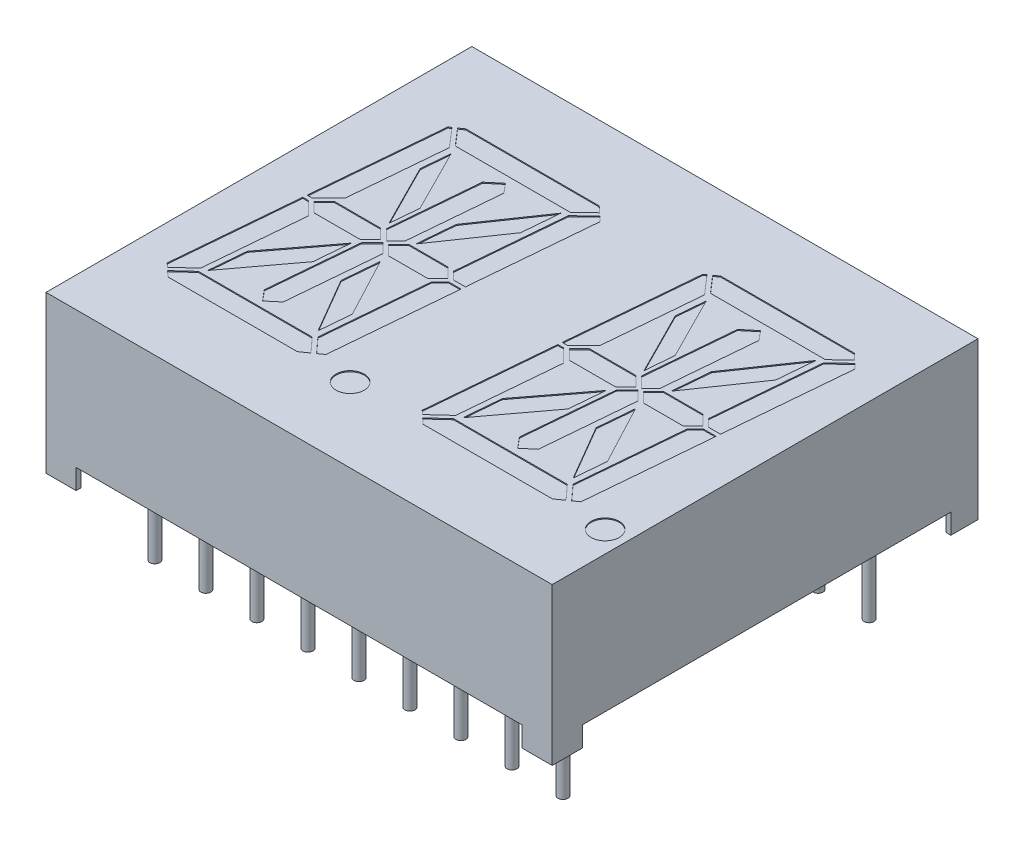
from build123d import *
from build123d.topology import SkipClean

# Parameters (mm, degrees)
SKETCH1_W           = 25.2
SKETCH1_H           = 21.2
EXTRUDE2_DEPTH      = 7.8
SKETCH6_R           = 0.7
CUT_EXTRUDE4_DEPTH  = 0.05
SKETCH7_R           = 0.25
EXTRUDE4_DEPTH      = 4
SKETCH9_W           = 18.348433105
SKETCH9_H           = 1
CUT_EXTRUDE7_DEPTH  = 26.2
SKETCH10_W          = 22.2
SKETCH10_H          = 1
CUT_EXTRUDE8_DEPTH  = 22.2
SKETCH7_5_R         = 0.25
EXTRUDE5_DEPTH      = 1
SKETCH11_W          = 1.25
SKETCH11_H          = 1.25
CUT_EXTRUDE9_DEPTH  = 1
CUT_EXTRUDE10_DEPTH = 0.01


with BuildPart() as part:
    # Sketch1 → Extrude2 (new body)
    with BuildSketch(Plane(origin=(0, 0, 0), x_dir=(1, 0, 0), z_dir=(0, 1, 0))):
        Rectangle(SKETCH1_W, SKETCH1_H)
    extrude(amount=-EXTRUDE2_DEPTH)

    # Sketch6 → Cut-Extrude4 (cut)
    with BuildSketch(Plane(origin=(0, 0, 0), x_dir=(-1, 0, 0), z_dir=(0, 1, 0))):
        Polygon((9.605999477, -6.616187167), (9.728673676, -6.530289768), (10.291898135, -0.092604746), (10.035400369, -0.092604746), (9.216427451, -0.911577664), (8.798795212, -5.685135996), align=None)
        Polygon((2.559776652, -6.9), (9.200672745, -6.9), (9.441289258, -6.731518504), (8.720377987, -5.9), (2.994935635, -5.9), (2.250088844, -6.611800258), align=None)
        Polygon((10.020609861, 0.107395254), (10.309395867, 0.107395254), (10.852711709, 6.317523737), (10.65894543, 6.497845306), (9.79555928, 5.70792943), (9.363100633, 0.764904482), align=None)
        Polygon((7.038868182, -0.5), (9.345162402, -0.5), (9.845162402, 0), (9.345162402, 0.5), (7.038868182, 0.5), (6.538868182, 0), align=None)
        Polygon((1.853806971, -6.243014886), (2.103427529, -6.475315217), (2.90425827, -5.710014842), (3.364278997, -0.451953879), (2.986541671, -0.074216552), (2.393506893, -0.074216552), align=None)
        Polygon((9.709205914, 5.9), (10.512062218, 6.634536847), (10.22680623, 6.9), (3.789953129, 6.9), (3.390407496, 6.620235136), (4.045891213, 5.9), align=None)
        Polygon((2.952360679, 6.313511453), (2.411004626, 0.125783448), (3.038108566, 0.125783448), (3.450942777, 0.538617658), (3.907326798, 5.755110894), (3.225236367, 6.504581066), align=None)
        Polygon((3.195167831, 0), (3.695167831, -0.5), (5.646011281, -0.5), (6.146011281, 0), (5.646011281, 0.5), (3.695167831, 0.5), align=None)
        Polygon((6.872327956, -0.616302487), (6.342439732, -0.086414262), (5.873873059, -0.554980935), (5.478245106, -5.077029138), (5.865446029, -5.53847723), (6.487348378, -5.016639198), align=None)
        Polygon((6.356343818, 0.072510176), (6.889004212, 0.60517057), (7.278335905, 5.055252177), (6.838171018, 5.579820263), (6.279388662, 5.110946195), (5.880236612, 0.548617382), align=None)
        Polygon((-5.661131818, 0.5), (-6.161131818, 0), (-5.661131818, -0.5), (-3.354837598, -0.5), (-2.854837598, 0), (-3.354837598, 0.5), align=None)
        Polygon((-2.90444072, 5.70792943), (-3.336899367, 0.764904482), (-2.679390139, 0.107395254), (-2.390604133, 0.107395254), (-1.847288291, 6.317523737), (-2.04105457, 6.497845306), align=None)
        Polygon((-2.664599631, -0.092604746), (-3.483572549, -0.911577664), (-3.901204788, -5.685135996), (-3.094000523, -6.616187167), (-2.971326324, -6.530289768), (-2.408101865, -0.092604746), align=None)
        Polygon((-8.654108787, 5.9), (-2.990794086, 5.9), (-2.187937782, 6.634536847), (-2.47319377, 6.9), (-8.910046871, 6.9), (-9.309592504, 6.620235136), align=None)
        Polygon((-3.258710742, -6.731518504), (-3.979622013, -5.9), (-9.705064365, -5.9), (-10.449911156, -6.611800258), (-10.140223348, -6.9), (-3.499327255, -6.9), align=None)
        Polygon((-8.792673202, 5.755110894), (-9.474763633, 6.504581066), (-9.747639321, 6.313511453), (-10.288995374, 0.125783448), (-9.661891434, 0.125783448), (-9.249057223, 0.538617658), align=None)
        Polygon((-10.596572471, -6.475315217), (-9.79574173, -5.710014842), (-9.335721003, -0.451953879), (-9.713458329, -0.074216552), (-10.306493107, -0.074216552), (-10.846193029, -6.243014886), align=None)
        Polygon((-9.504832169, 0), (-9.004832169, -0.5), (-7.053988719, -0.5), (-6.553988719, 0), (-7.053988719, 0.5), (-9.004832169, 0.5), align=None)
        Polygon((-6.343656182, 0.072510176), (-5.810995788, 0.60517057), (-5.421664095, 5.055252177), (-5.861828982, 5.579820263), (-6.420611338, 5.110946195), (-6.819763388, 0.548617382), align=None)
        Polygon((-7.383790018, -2.547446043), (-7.221754894, -0.695376112), (-9.342797046, -3.784227143), (-9.504832169, -5.636297074), align=None)
        Polygon((-3.340370794, 3.813758604), (-3.181274716, 5.632235103), (-5.421664095, 2.635352461), (-5.575460304, 0.877453747), align=None)
        Polygon((-7.221754894, -5.077029138), (-6.834553971, -5.53847723), (-6.212651622, -5.016639198), (-5.827672044, -0.616302487), (-6.357560268, -0.086414262), (-6.826126941, -0.554980935), align=None)
        Polygon((-4.079807546, -4.045143648), (-5.661131818, -0.911577664), (-5.78559396, -2.334186454), (-4.204269688, -5.467752438), align=None)
        Polygon((-6.931214255, 2.743151651), (-8.528606301, 5.481963247), (-8.665710502, 3.914855052), (-7.089074735, 0.938798114), align=None)
        Polygon((6.91440604, -2.334186454), (8.495730312, -5.467752438), (8.620192454, -4.045143648), (7.038868182, -0.911577664), align=None)
        Polygon((3.195167831, -5.636297074), (5.316209982, -2.547446043), (5.478245106, -0.695376112), (3.357202954, -3.784227143), align=None)
        Polygon((7.124539696, 0.877453747), (9.359629206, 3.813758604), (9.518725284, 5.632235103), (7.278335905, 2.635352461), align=None)
        Polygon((4.034289498, 3.914855052), (5.610925265, 0.938798114), (5.768785745, 2.743151651), (4.171393699, 5.481963247), align=None)
        with Locations(Location((1.160151729, 6.9, 0), (0, 0, 90))):  # turned: the seam where the file's is
            Circle(SKETCH6_R)
        with Locations(Location((-11.539848271, 6.9, 0), (0, 0, 90))):  # turned: the seam where the file's is
            Circle(SKETCH6_R)
    extrude(amount=-CUT_EXTRUDE4_DEPTH, mode=Mode.SUBTRACT)

    # Sketch7 → Extrude4 (add)
    with BuildSketch(Plane.XZ.offset(7.8)):
        with Locations(Location((-7.62, 7.62, 0), (0, 0, 90))):  # turned: the seam where the file's is
            Circle(SKETCH7_R)
        with Locations(Location((-5.08, 7.62, 0), (0, 0, 90))):  # turned: the seam where the file's is
            Circle(SKETCH7_R)
        with Locations(Location((-2.54, 7.62, 0), (0, 0, 90))):  # turned: the seam where the file's is
            Circle(SKETCH7_R)
        with Locations(Location((0, 7.62, 0), (0, 0, 90))):  # turned: the seam where the file's is
            Circle(SKETCH7_R)
        with Locations(Location((2.54, 7.62, 0), (0, 0, 90))):  # turned: the seam where the file's is
            Circle(SKETCH7_R)
        with Locations(Location((5.08, 7.62, 0), (0, 0, 90))):  # turned: the seam where the file's is
            Circle(SKETCH7_R)
        with Locations(Location((7.62, 7.62, 0), (0, 0, 90))):  # turned: the seam where the file's is
            Circle(SKETCH7_R)
        with Locations(Location((10.16, 7.62, 0), (0, 0, 90))):  # turned: the seam where the file's is
            Circle(SKETCH7_R)
        with Locations(Location((-10.16, 7.62, 0), (0, 0, 90))):  # turned: the seam where the file's is
            Circle(SKETCH7_R)
        with Locations(Location((-10.16, -7.62, 0), (0, 0, 180))):  # turned: the seam where the file's is
            Circle(SKETCH7_R)
        with Locations(Location((10.16, -7.62, 0), (0, 0, 180))):  # turned: the seam where the file's is
            Circle(SKETCH7_R)
        with Locations(Location((7.62, -7.62, 0), (0, 0, 180))):  # turned: the seam where the file's is
            Circle(SKETCH7_R)
        with Locations(Location((5.08, -7.62, 0), (0, 0, 180))):  # turned: the seam where the file's is
            Circle(SKETCH7_R)
        with Locations(Location((2.54, -7.62, 0), (0, 0, 180))):  # turned: the seam where the file's is
            Circle(SKETCH7_R)
        with Locations(Location((0, -7.62, 0), (0, 0, 180))):  # turned: the seam where the file's is
            Circle(SKETCH7_R)
        with Locations(Location((-2.54, -7.62, 0), (0, 0, 180))):  # turned: the seam where the file's is
            Circle(SKETCH7_R)
        with Locations(Location((-5.08, -7.62, 0), (0, 0, 180))):  # turned: the seam where the file's is
            Circle(SKETCH7_R)
        with Locations(Location((-7.62, -7.62, 0), (0, 0, 180))):  # turned: the seam where the file's is
            Circle(SKETCH7_R)
    extrude(amount=EXTRUDE4_DEPTH)

    # Sketch9 → Cut-Extrude7 (cut, through all)
    with BuildSketch(Plane(origin=(12.6, 0, 0), x_dir=(0, 0, -1), z_dir=(1, 0, 0))):
        with Locations((0.074216552, -7.3)):
            Rectangle(SKETCH9_W, SKETCH9_H)
    extrude(amount=-CUT_EXTRUDE7_DEPTH, mode=Mode.SUBTRACT)

    # Sketch10 → Cut-Extrude8 (cut, through all)
    with BuildSketch(Plane.XY.offset(10.6)):
        with Locations((0, -7.3)):
            Rectangle(SKETCH10_W, SKETCH10_H)
    extrude(amount=-CUT_EXTRUDE8_DEPTH, mode=Mode.SUBTRACT)

    # Sketch7_5 → Extrude5 (add)
    with SkipClean():  # keep this step's faces unmerged: merging them makes the solid invalid here
        with BuildSketch(Plane.XZ.offset(7.8)):
            with Locations((-7.62, 7.62)):
                Circle(SKETCH7_5_R)
            with Locations((-5.08, 7.62)):
                Circle(SKETCH7_5_R)
            with Locations((-2.54, 7.62)):
                Circle(SKETCH7_5_R)
            with Locations((0, 7.62)):
                Circle(SKETCH7_5_R)
            with Locations((2.54, 7.62)):
                Circle(SKETCH7_5_R)
            with Locations((5.08, 7.62)):
                Circle(SKETCH7_5_R)
            with Locations((7.62, 7.62)):
                Circle(SKETCH7_5_R)
            with Locations((10.16, 7.62)):
                Circle(SKETCH7_5_R)
            with Locations((-10.16, 7.62)):
                Circle(SKETCH7_5_R)
            with Locations(Location((-10.16, -7.62, 0), (0, 0, 180))):  # turned: the seam where the file's is
                Circle(SKETCH7_5_R)
            with Locations(Location((10.16, -7.62, 0), (0, 0, 180))):  # turned: the seam where the file's is
                Circle(SKETCH7_5_R)
            with Locations(Location((7.62, -7.62, 0), (0, 0, 180))):  # turned: the seam where the file's is
                Circle(SKETCH7_5_R)
            with Locations(Location((5.08, -7.62, 0), (0, 0, 180))):  # turned: the seam where the file's is
                Circle(SKETCH7_5_R)
            with Locations(Location((2.54, -7.62, 0), (0, 0, 90))):  # turned: the seam where the file's is
                Circle(SKETCH7_5_R)
            with Locations(Location((0, -7.62, 0), (0, 0, 180))):  # turned: the seam where the file's is
                Circle(SKETCH7_5_R)
            with Locations(Location((-2.54, -7.62, 0), (0, 0, 180))):  # turned: the seam where the file's is
                Circle(SKETCH7_5_R)
            with Locations(Location((-5.08, -7.62, 0), (0, 0, 180))):  # turned: the seam where the file's is
                Circle(SKETCH7_5_R)
            with Locations(Location((-7.62, -7.62, 0), (0, 0, 180))):  # turned: the seam where the file's is
                Circle(SKETCH7_5_R)
        extrude(amount=-EXTRUDE5_DEPTH)

    # Sketch11 → Cut-Extrude9 (cut)
    with SkipClean():  # keep this step's faces unmerged: merging them makes the solid invalid here
        with BuildSketch(Plane.XZ.offset(7.8)):
            with Locations((-11.725, 9.725)):
                Rectangle(SKETCH11_W, SKETCH11_H)
            with Locations((11.725, 9.725)):
                Rectangle(SKETCH11_W, SKETCH11_H)
            with Locations((11.725, -9.725)):
                Rectangle(SKETCH11_W, SKETCH11_H)
            with Locations((-11.725, -9.725)):
                Rectangle(SKETCH11_W, SKETCH11_H)
        extrude(amount=-CUT_EXTRUDE9_DEPTH, mode=Mode.SUBTRACT)

    # Sketch12 → Cut-Extrude10 (cut)
    with SkipClean():  # keep this step's faces unmerged: merging them makes the solid invalid here
        with BuildSketch(Plane.XZ.offset(6.8)):
            Polygon((-10.188863648, 0.564850288), (-10.264140547, 0.587021965), (-10.264496559, 0.612516427), (-10.214180104, 0.62849744), (-10.264931686, 0.642836838), (-10.265287699, 0.668667535), (-10.190643711, 0.692737946), (-10.190287699, 0.667500604), (-10.241771085, 0.653952345), (-10.189892129, 0.638663579), (-10.189595452, 0.617381933), (-10.241039281, 0.601420699), (-10.189199882, 0.589533832), align=None)
            Polygon((-10.18710614, 0.430684583), (-10.262383039, 0.452856261), (-10.262739052, 0.478350723), (-10.212422596, 0.494331735), (-10.263174178, 0.508671134), (-10.263530191, 0.53450183), (-10.188886204, 0.558572242), (-10.188530191, 0.5333349), (-10.240013577, 0.51978664), (-10.188134622, 0.504497875), (-10.187837944, 0.483216229), (-10.239281773, 0.467254995), (-10.187442375, 0.455368128), align=None)
            Polygon((-10.185348633, 0.296518879), (-10.260625532, 0.318690556), (-10.260981544, 0.344185018), (-10.210665089, 0.360166031), (-10.261416671, 0.37450543), (-10.261772684, 0.400336126), (-10.187128696, 0.424406537), (-10.186772684, 0.399169195), (-10.23825607, 0.385620936), (-10.186377114, 0.37033217), (-10.186080437, 0.349050525), (-10.237524266, 0.33308929), (-10.185684867, 0.321202423), align=None)
            Polygon((-10.259856948, 0.255015358), (-10.260193183, 0.279975801), (-10.233966917, 0.280331814), (-10.233630683, 0.255371371), align=None)
            with BuildLine():
                add(Edge.make_bspline(
                    [(-10.227188958, 0.15102434), (-10.228391193, 0.151038896), (-10.23075023, 0.151067459), (-10.234195423, 0.151648788), (-10.237467841, 0.152579751), (-10.240588651, 0.153888157), (-10.24352345, 0.155634682), (-10.246313419, 0.15774013), (-10.248913882, 0.160257073), (-10.251316351, 0.163148262), (-10.253504194, 0.166365646), (-10.255436473, 0.169884181), (-10.257043866, 0.173696031), (-10.258397079, 0.177775579), (-10.259457333, 0.182142422), (-10.260242289, 0.186788197), (-10.260739805, 0.191718183), (-10.260840017, 0.195096228), (-10.260891489, 0.196831302)],
                    knots=[0, 0, 0, 0, 0.905613325, 1.777001275, 2.625271516, 3.467501776, 4.321117884, 5.194248966, 6.098004004, 7.044033582, 8.024582809, 9.028158843, 10.066246198, 11.140165378, 12.266524364, 13.451802169, 14.691162558, 16, 16, 16, 16], degree=3))
                add(Edge.make_bspline(
                    [(-10.260891489, 0.196831302), (-10.260893752, 0.198822943), (-10.260898133, 0.202677612), (-10.260544632, 0.208267974), (-10.259989734, 0.213472863), (-10.259064002, 0.218309921), (-10.257963585, 0.222877277), (-10.256710556, 0.227267473), (-10.25534697, 0.23152716), (-10.254279397, 0.234276882), (-10.253751458, 0.235636682)],
                    knots=[0, 0, 0, 0, 1.202662399, 2.327661513, 3.381753041, 4.361947527, 5.299787602, 6.218728123, 7.119120944, 8, 8, 8, 8], degree=3))
                Line((-10.253751458, 0.235636682), (-10.229918388, 0.235972916))
                Line((-10.229918388, 0.235972916), (-10.229878831, 0.233164372))
                add(Edge.make_bspline(
                    [(-10.229878831, 0.233164372), (-10.230878398, 0.231802597), (-10.232875357, 0.22908201), (-10.235450418, 0.224698547), (-10.237647399, 0.220083396), (-10.239443419, 0.215286504), (-10.240870709, 0.210435386), (-10.241850813, 0.205624621), (-10.242468835, 0.200915546), (-10.242501285, 0.197808867), (-10.24251728, 0.196277505)],
                    knots=[0, 0, 0, 0, 1.020944444, 2.039668214, 3.068559681, 4.108131038, 5.133796854, 6.122828867, 7.074693892, 8, 8, 8, 8], degree=3))
                add(Edge.make_bspline(
                    [(-10.24251728, 0.196277505), (-10.242507653, 0.195855396), (-10.242487025, 0.194950929), (-10.242375607, 0.193507617), (-10.242239571, 0.19187842), (-10.242060043, 0.190127179), (-10.241779636, 0.188374709), (-10.241484831, 0.186737003), (-10.24108723, 0.185276667), (-10.24075645, 0.184381998), (-10.240598768, 0.183955511)],
                    knots=[0, 0, 0, 0, 0.808883124, 1.733225854, 2.772869213, 3.941916762, 5.10501109, 6.172823497, 7.128989411, 8, 8, 8, 8], degree=3))
                add(Edge.make_bspline(
                    [(-10.240598768, 0.183955511), (-10.240389644, 0.183483348), (-10.239983066, 0.182565369), (-10.239249097, 0.181291427), (-10.238425288, 0.180165173), (-10.237573339, 0.179129906), (-10.236534616, 0.178271951), (-10.235256522, 0.177710865), (-10.233780209, 0.177367053), (-10.232729077, 0.177342634), (-10.232173135, 0.17732972)],
                    knots=[0, 0, 0, 0, 1.073104943, 2.086332613, 3.048687859, 3.971889032, 4.868770994, 5.819341853, 6.846654952, 8, 8, 8, 8], degree=3))
                add(Edge.make_bspline(
                    [(-10.232173135, 0.17732972), (-10.231640567, 0.177369529), (-10.230593858, 0.177447771), (-10.229102166, 0.178023391), (-10.227729181, 0.178911531), (-10.226496501, 0.180168111), (-10.225417539, 0.181760599), (-10.224440697, 0.183654434), (-10.223645063, 0.185880813), (-10.22324516, 0.187485278), (-10.223035477, 0.188326555)],
                    knots=[0, 0, 0, 0, 0.825813695, 1.623055451, 2.452671838, 3.350787127, 4.336774948, 5.431670048, 6.653333383, 8, 8, 8, 8], degree=3))
                add(Edge.make_bspline(
                    [(-10.223035477, 0.188326555), (-10.222619115, 0.190249008), (-10.221764437, 0.194195287), (-10.220743684, 0.200211987), (-10.219596228, 0.206210449), (-10.21845114, 0.210077298), (-10.217893072, 0.21196184)],
                    knots=[0, 0, 0, 0, 0.975106471, 2.001631468, 3.026077723, 4, 4, 4, 4], degree=3))
                add(Edge.make_bspline(
                    [(-10.217893072, 0.21196184), (-10.217570242, 0.21298187), (-10.216941066, 0.214969845), (-10.215799524, 0.217793375), (-10.214603649, 0.220407106), (-10.21331348, 0.222806241), (-10.211916879, 0.224974974), (-10.210420276, 0.226930955), (-10.208849249, 0.228683439), (-10.207142033, 0.230193726), (-10.205355094, 0.231533828), (-10.203450607, 0.232680926), (-10.201440447, 0.233649264), (-10.199334854, 0.23447043), (-10.197115412, 0.235100115), (-10.194785424, 0.235548108), (-10.192353812, 0.235856474), (-10.190692022, 0.235907446), (-10.189847185, 0.235933359)],
                    knots=[0, 0, 0, 0, 1.282805832, 2.500108526, 3.649972799, 4.729145314, 5.764432439, 6.740272019, 7.680707182, 8.582342914, 9.469577274, 10.356494431, 11.244186773, 12.142905032, 13.063992032, 14.006884118, 14.98672037, 16, 16, 16, 16], degree=3))
                add(Edge.make_bspline(
                    [(-10.189847185, 0.235933359), (-10.188710679, 0.235919118), (-10.186482264, 0.235891195), (-10.183221623, 0.235304116), (-10.180113991, 0.234373314), (-10.177140781, 0.233070892), (-10.174351662, 0.231321696), (-10.171732241, 0.229179579), (-10.169245185, 0.226673623), (-10.16695499, 0.223791893), (-10.164865602, 0.220613354), (-10.163018658, 0.217181282), (-10.161463532, 0.213516179), (-10.160171394, 0.209626308), (-10.159149614, 0.205519772), (-10.158401254, 0.201183814), (-10.157918987, 0.196624237), (-10.157831185, 0.193503131), (-10.157786268, 0.19190646)],
                    knots=[0, 0, 0, 0, 0.897808362, 1.760386244, 2.610128471, 3.460062744, 4.319734508, 5.205955006, 6.131628878, 7.107429019, 8.112776413, 9.137167261, 10.186325449, 11.25836101, 12.3765717, 13.530694495, 14.736772209, 16, 16, 16, 16], degree=3))
                add(Edge.make_bspline(
                    [(-10.157786268, 0.19190646), (-10.157791474, 0.190277719), (-10.157801872, 0.187024326), (-10.158079034, 0.182151335), (-10.158617545, 0.17730049), (-10.159386194, 0.172524895), (-10.160325376, 0.167927455), (-10.161391435, 0.163596404), (-10.162577477, 0.1595833), (-10.163521406, 0.157052055), (-10.163976932, 0.155830511)],
                    knots=[0, 0, 0, 0, 1.061814009, 2.120962218, 3.180476718, 4.242630005, 5.273640008, 6.239039365, 7.150184742, 8, 8, 8, 8], degree=3))
                Line((-10.163976932, 0.155830511), (-10.186880413, 0.155514055))
                Line((-10.186880413, 0.155514055), (-10.18691997, 0.158243486))
                add(Edge.make_bspline(
                    [(-10.18691997, 0.158243486), (-10.186148947, 0.159298591), (-10.184566827, 0.161463641), (-10.182518489, 0.165032073), (-10.180646269, 0.168917962), (-10.179007362, 0.173086958), (-10.177641553, 0.177442043), (-10.176688445, 0.181903555), (-10.176137745, 0.186400326), (-10.176100143, 0.189412883), (-10.176081363, 0.190917536)],
                    knots=[0, 0, 0, 0, 0.89474966, 1.836003924, 2.813787682, 3.847991799, 4.902367641, 5.937114117, 6.96966969, 8, 8, 8, 8], degree=3))
                add(Edge.make_bspline(
                    [(-10.176081363, 0.190917536), (-10.176110831, 0.191986794), (-10.176169582, 0.194118537), (-10.176555275, 0.197287799), (-10.177178217, 0.200416879), (-10.177950365, 0.202391508), (-10.17833611, 0.203377979)],
                    knots=[0, 0, 0, 0, 1.006712549, 2.00704906, 3.004375525, 4, 4, 4, 4], degree=3))
                add(Edge.make_bspline(
                    [(-10.17833611, 0.203377979), (-10.178519405, 0.203796971), (-10.178884002, 0.204630401), (-10.179569085, 0.205811496), (-10.1804439, 0.206857071), (-10.181393847, 0.207822507), (-10.182440911, 0.208644349), (-10.183602795, 0.209204509), (-10.184821766, 0.209562313), (-10.185664853, 0.209592835), (-10.186089274, 0.209608201)],
                    knots=[0, 0, 0, 0, 1.038377586, 2.065468124, 3.087307206, 4.124820917, 5.139947075, 6.090763943, 7.038865704, 8, 8, 8, 8], degree=3))
                add(Edge.make_bspline(
                    [(-10.186089274, 0.209608201), (-10.186715548, 0.209576524), (-10.187914078, 0.209515903), (-10.189574374, 0.208871947), (-10.191033341, 0.207919288), (-10.191975255, 0.20675371), (-10.192656315, 0.205658849), (-10.193144364, 0.204641431), (-10.193613667, 0.203456678), (-10.194060688, 0.202105466), (-10.194522894, 0.200598894), (-10.19495041, 0.198920995), (-10.195364449, 0.197072676), (-10.195624954, 0.19578356), (-10.195760951, 0.195110574)],
                    knots=[0, 0, 0, 0, 1.175175981, 2.248991921, 3.314427576, 4.42552043, 5.039602249, 5.745697853, 6.549060383, 7.441464155, 8.428593066, 9.520109677, 10.705368694, 12, 12, 12, 12], degree=3))
                add(Edge.make_bspline(
                    [(-10.195760951, 0.195110574), (-10.196110095, 0.193317236), (-10.19679454, 0.189801653), (-10.197826099, 0.184529276), (-10.198999699, 0.179155404), (-10.200055944, 0.175563386), (-10.200606679, 0.173690479)],
                    knots=[0, 0, 0, 0, 0.997744368, 1.955934644, 2.934207933, 4, 4, 4, 4], degree=3))
                add(Edge.make_bspline(
                    [(-10.200606679, 0.173690479), (-10.200906259, 0.172763896), (-10.201491755, 0.17095299), (-10.202523227, 0.168357479), (-10.203650858, 0.165953024), (-10.20483547, 0.163717674), (-10.206116269, 0.161675197), (-10.207508507, 0.159830422), (-10.208975534, 0.158163908), (-10.21051686, 0.15665663), (-10.212198443, 0.155375066), (-10.213970582, 0.154229808), (-10.215872161, 0.153262082), (-10.217899302, 0.152468363), (-10.22005364, 0.151856388), (-10.222323129, 0.151410956), (-10.224714971, 0.151099155), (-10.226350652, 0.151049691), (-10.227188958, 0.15102434)],
                    knots=[0, 0, 0, 0, 1.233451265, 2.41064625, 3.535352088, 4.596582514, 5.613845531, 6.586050284, 7.521056099, 8.424838794, 9.3119497, 10.194685429, 11.094910519, 12.010007478, 12.94847622, 13.92800822, 14.938079578, 16, 16, 16, 16], degree=3))
            make_face()
            with BuildLine():
                Line((-10.25726117, 0.059339664), (-10.257577626, 0.083370518))
                Line((-10.257577626, 0.083370518), (-10.249290442, 0.083489189))
                add(Edge.make_bspline(
                    [(-10.249290442, 0.083489189), (-10.250109698, 0.084557524), (-10.25169018, 0.086618519), (-10.253841954, 0.089701828), (-10.255646906, 0.092673159), (-10.257248619, 0.095523085), (-10.258469208, 0.098490884), (-10.259334596, 0.1016782), (-10.259868087, 0.105135832), (-10.25996198, 0.107531303), (-10.260010379, 0.108766088)],
                    knots=[0, 0, 0, 0, 1.151538396, 2.221509531, 3.213824037, 4.12474945, 5.014892842, 5.950667409, 6.943638669, 8, 8, 8, 8], degree=3))
                add(Edge.make_bspline(
                    [(-10.260010379, 0.108766088), (-10.260008699, 0.109775532), (-10.260005442, 0.111733437), (-10.259701663, 0.114587241), (-10.259170918, 0.117261742), (-10.258421216, 0.11976794), (-10.257450607, 0.122097279), (-10.256253575, 0.124255673), (-10.254831561, 0.126244861), (-10.253150063, 0.12803168), (-10.251265907, 0.129635882), (-10.24917273, 0.131060222), (-10.246847805, 0.132238006), (-10.244313657, 0.133208834), (-10.241571527, 0.133975928), (-10.238615661, 0.13454701), (-10.23544093, 0.134905888), (-10.233251061, 0.134962951), (-10.232122721, 0.134992353)],
                    knots=[0, 0, 0, 0, 1.108215295, 2.149480832, 3.146491206, 4.099557658, 5.018159392, 5.912871712, 6.805236318, 7.696777763, 8.600877983, 9.518794364, 10.471007517, 11.456803283, 12.495320249, 13.594602776, 14.760607326, 16, 16, 16, 16], degree=3))
                Line((-10.232122721, 0.134992353), (-10.183329208, 0.1356846))
                Line((-10.183329208, 0.1356846), (-10.182992974, 0.111515297))
                Line((-10.182992974, 0.111515297), (-10.220176518, 0.111001056))
                add(Edge.make_bspline(
                    [(-10.220176518, 0.111001056), (-10.221079792, 0.110983975), (-10.222814269, 0.110951176), (-10.225294572, 0.11086157), (-10.227543325, 0.110699431), (-10.229561603, 0.110503258), (-10.231389054, 0.110275405), (-10.233020988, 0.109855856), (-10.234518762, 0.109396476), (-10.23541145, 0.108930847), (-10.235841075, 0.108706752)],
                    knots=[0, 0, 0, 0, 1.35737069, 2.606438506, 3.728554873, 4.743753814, 5.654300366, 6.490357112, 7.273450953, 8, 8, 8, 8], degree=3))
                add(Edge.make_bspline(
                    [(-10.235841075, 0.108706752), (-10.236233233, 0.108476632), (-10.237004617, 0.108023981), (-10.23799219, 0.107103844), (-10.238803619, 0.106031013), (-10.239456472, 0.104783264), (-10.239926638, 0.103333044), (-10.240230514, 0.101644044), (-10.240403635, 0.099711266), (-10.240407738, 0.098336619), (-10.240409904, 0.097611024)],
                    knots=[0, 0, 0, 0, 0.85748724, 1.686698362, 2.531776109, 3.390349692, 4.336305081, 5.402109472, 6.628727169, 8, 8, 8, 8], degree=3))
                add(Edge.make_bspline(
                    [(-10.240409904, 0.097611024), (-10.240384081, 0.097083058), (-10.240331286, 0.096003613), (-10.240110737, 0.094341677), (-10.239724799, 0.092606711), (-10.239041612, 0.090168798), (-10.23781825, 0.087099084), (-10.23644142, 0.084823085), (-10.235742183, 0.083667195)],
                    knots=[0, 0, 0, 0, 0.639123329, 1.306709163, 2.024544137, 2.786835856, 4.368160791, 6, 6, 6, 6], degree=3))
                Line((-10.235742183, 0.083667195), (-10.182617183, 0.084418778))
                Line((-10.182617183, 0.084418778), (-10.182300727, 0.060387923))
                Line((-10.182300727, 0.060387923), (-10.25726117, 0.059339664))
            make_face()
            with BuildLine():
                Line((-10.255964712, -0.038733462), (-10.256300946, -0.014564158))
                Line((-10.256300946, -0.014564158), (-10.219117402, -0.014049918))
                add(Edge.make_bspline(
                    [(-10.219117402, -0.014049918), (-10.217607011, -0.014005466), (-10.214594186, -0.013916796), (-10.210884193, -0.013588011), (-10.208085783, -0.013168952), (-10.20626699, -0.012816554), (-10.204745996, -0.012352442), (-10.203871207, -0.01194243), (-10.203472623, -0.011755614)],
                    knots=[0, 0, 0, 0, 1.708795158, 3.408586981, 4.20790055, 4.908349896, 5.502607328, 6, 6, 6, 6], degree=3))
                add(Edge.make_bspline(
                    [(-10.203472623, -0.011755614), (-10.203080063, -0.011518979), (-10.202307008, -0.01105298), (-10.201327279, -0.010113729), (-10.200509441, -0.009041093), (-10.199856648, -0.007792518), (-10.199388249, -0.006334178), (-10.199065493, -0.004647686), (-10.198863722, -0.00271512), (-10.198864059, -0.001346088), (-10.198864237, -0.000620329)],
                    knots=[0, 0, 0, 0, 0.862241858, 1.697983262, 2.541093037, 3.397667221, 4.34141972, 5.419329638, 6.631920516, 8, 8, 8, 8], degree=3))
                add(Edge.make_bspline(
                    [(-10.198864237, -0.000620329), (-10.198934049, 0.000479215), (-10.199076861, 0.002728512), (-10.199828018, 0.005507014), (-10.200659124, 0.007768952), (-10.201452206, 0.009556586), (-10.202434486, 0.011392249), (-10.203158481, 0.012627139), (-10.203531959, 0.013264164)],
                    knots=[0, 0, 0, 0, 1.335107873, 2.731181929, 3.473299394, 4.2617711, 5.103323931, 6, 6, 6, 6], degree=3))
                Line((-10.203531959, 0.013264164), (-10.256676737, 0.012532361))
                Line((-10.256676737, 0.012532361), (-10.257012971, 0.036563215))
                Line((-10.257012971, 0.036563215), (-10.182052528, 0.037611475))
                Line((-10.182052528, 0.037611475), (-10.181716294, 0.01358062))
                Line((-10.181716294, 0.01358062), (-10.189983699, 0.013461949))
                add(Edge.make_bspline(
                    [(-10.189983699, 0.013461949), (-10.189175828, 0.012421306), (-10.187603088, 0.010395413), (-10.185478615, 0.007316133), (-10.183676521, 0.004275224), (-10.182123278, 0.001285702), (-10.180847581, -0.001760466), (-10.179998838, -0.004975966), (-10.179422243, -0.008346707), (-10.179330304, -0.010658758), (-10.179283541, -0.011834728)],
                    knots=[0, 0, 0, 0, 1.127811704, 2.19558969, 3.200417328, 4.152141816, 5.078744857, 6.020846203, 6.993350802, 8, 8, 8, 8], degree=3))
                add(Edge.make_bspline(
                    [(-10.179283541, -0.011834728), (-10.179293816, -0.012817813), (-10.179313935, -0.014742671), (-10.179614478, -0.017548641), (-10.180122359, -0.020191497), (-10.180856755, -0.022672614), (-10.181823452, -0.024988032), (-10.183020668, -0.027141919), (-10.184433226, -0.029137631), (-10.186076172, -0.030960445), (-10.187950644, -0.032590682), (-10.190037578, -0.034024058), (-10.192358912, -0.035233485), (-10.194891278, -0.036237066), (-10.197646366, -0.037031526), (-10.200625853, -0.037596944), (-10.203827189, -0.037949132), (-10.206036341, -0.038023031), (-10.207171199, -0.038060994)],
                    knots=[0, 0, 0, 0, 1.080956487, 2.116488353, 3.099278902, 4.037722294, 4.957628454, 5.853611276, 6.743025069, 7.641616204, 8.546244778, 9.469546437, 10.420018076, 11.419260365, 12.461247675, 13.569210615, 14.751285353, 16, 16, 16, 16], degree=3))
                Line((-10.207171199, -0.038060994), (-10.255964712, -0.038733462))
            make_face()
            Polygon((-10.254727589, -0.13391893), (-10.255716513, -0.062221936), (-10.156329646, -0.060837442), (-10.155973633, -0.086470354), (-10.236135817, -0.087597727), (-10.235502905, -0.133661809), align=None)
            Polygon((-10.253583551, -0.221450994), (-10.254572475, -0.149556215), (-10.155185608, -0.148171722), (-10.154196684, -0.2200665), (-10.173421367, -0.220343399), (-10.174054279, -0.173962861), (-10.191202222, -0.174200203), (-10.190608867, -0.217238177), (-10.209833551, -0.217495298), (-10.210426905, -0.174457323), (-10.234991779, -0.174813336), (-10.234358867, -0.221193874), align=None)
            with BuildLine():
                add(Edge.make_bspline(
                    [(-10.202435726, -0.336454825), (-10.203576614, -0.336447134), (-10.205834649, -0.336431913), (-10.209185424, -0.336198132), (-10.21244233, -0.335743539), (-10.21561226, -0.335083776), (-10.218693647, -0.334239611), (-10.221692019, -0.333184072), (-10.224602368, -0.331941292), (-10.227404501, -0.330495046), (-10.230076654, -0.328895627), (-10.232621498, -0.327198221), (-10.234992675, -0.325373008), (-10.237220889, -0.323454165), (-10.239276815, -0.32141316), (-10.24117799, -0.319272387), (-10.242937879, -0.31703612), (-10.243968943, -0.315451641), (-10.244484776, -0.314658939)],
                    knots=[0, 0, 0, 0, 1.106373812, 2.189725018, 3.254979297, 4.293333585, 5.328039149, 6.351321031, 7.373963412, 8.394905172, 9.407078834, 10.393123119, 11.359989816, 12.307398659, 13.243344914, 14.167310386, 15.083119762, 16, 16, 16, 16], degree=3))
                add(Edge.make_bspline(
                    [(-10.244484776, -0.314658939), (-10.245198573, -0.313437564), (-10.246625794, -0.310995453), (-10.248386753, -0.307108411), (-10.249816118, -0.303044639), (-10.250898424, -0.298750146), (-10.251737234, -0.29417113), (-10.252295523, -0.289220144), (-10.252737089, -0.283877895), (-10.252812216, -0.280179456), (-10.252851074, -0.278266534)],
                    knots=[0, 0, 0, 0, 0.897044066, 1.793619926, 2.702435138, 3.626636327, 4.600465682, 5.653658324, 6.786414923, 8, 8, 8, 8], degree=3))
                Line((-10.252851074, -0.278266534), (-10.253345536, -0.243219066))
                Line((-10.253345536, -0.243219066), (-10.153958669, -0.241834572))
                Line((-10.153958669, -0.241834572), (-10.153464207, -0.277890743))
                add(Edge.make_bspline(
                    [(-10.153464207, -0.277890743), (-10.153458197, -0.279849132), (-10.153446614, -0.2836235), (-10.153739642, -0.289084949), (-10.154304206, -0.294131508), (-10.155130058, -0.298783394), (-10.156202926, -0.303048484), (-10.157460455, -0.306969296), (-10.158941397, -0.310550123), (-10.160167843, -0.312731216), (-10.160762466, -0.313788686)],
                    knots=[0, 0, 0, 0, 1.267308878, 2.442460688, 3.537543156, 4.551961882, 5.497846529, 6.381679369, 7.215382422, 8, 8, 8, 8], degree=3))
                add(Edge.make_bspline(
                    [(-10.160762466, -0.313788686), (-10.161283945, -0.314640917), (-10.162317719, -0.316330372), (-10.164083272, -0.318707642), (-10.165954699, -0.320969503), (-10.167986217, -0.323087358), (-10.170131938, -0.32509253), (-10.172446161, -0.326930986), (-10.174876889, -0.328657283), (-10.17745108, -0.330240623), (-10.180149169, -0.331665198), (-10.182984396, -0.332891191), (-10.185924601, -0.333967889), (-10.189002383, -0.334828219), (-10.192190084, -0.335531055), (-10.195503514, -0.336005289), (-10.198927457, -0.336364388), (-10.201254647, -0.336424379), (-10.202435726, -0.336454825)],
                    knots=[0, 0, 0, 0, 0.964432455, 1.911881411, 2.856695377, 3.797898411, 4.744020078, 5.690634344, 6.649861756, 7.621726318, 8.607115393, 9.593635126, 10.60268276, 11.6285437, 12.677556308, 13.752676103, 14.859454424, 16, 16, 16, 16], degree=3))
            make_face()
            with BuildLine():
                add(Edge.make_bspline(
                    [(-10.202613732, -0.30995166), (-10.201035112, -0.309886703), (-10.197979354, -0.309760963), (-10.193584305, -0.309023508), (-10.18955121, -0.307858348), (-10.186450851, -0.306520963), (-10.18419161, -0.305189932), (-10.182596564, -0.304074071), (-10.18109653, -0.302835511), (-10.179702534, -0.301451387), (-10.178396558, -0.299957999), (-10.177207851, -0.298314118), (-10.17609464, -0.296561597), (-10.175448677, -0.295314197), (-10.175121643, -0.294682673)],
                    knots=[0, 0, 0, 0, 1.706902978, 3.304077528, 4.804057967, 6.237035258, 6.939949068, 7.635998994, 8.339635224, 9.040232286, 9.757704128, 10.481942062, 11.231449463, 12, 12, 12, 12], degree=3))
                add(Edge.make_bspline(
                    [(-10.175121643, -0.294682673), (-10.174819156, -0.294021752), (-10.174220578, -0.292713888), (-10.173547986, -0.290685032), (-10.172974904, -0.288656743), (-10.172572201, -0.286519194), (-10.172291265, -0.284107597), (-10.172136498, -0.281268189), (-10.172026316, -0.277911268), (-10.172058486, -0.275504235), (-10.172075757, -0.274211945)],
                    knots=[0, 0, 0, 0, 0.833913937, 1.6501894, 2.450837699, 3.252487255, 4.144433124, 5.236563854, 6.516364282, 8, 8, 8, 8], degree=3))
                Line((-10.172075757, -0.274211945), (-10.172154871, -0.267724604))
                Line((-10.172154871, -0.267724604), (-10.234358194, -0.268594857))
                Line((-10.234358194, -0.268594857), (-10.23427908, -0.275082198))
                add(Edge.make_bspline(
                    [(-10.23427908, -0.275082198), (-10.234269536, -0.27582069), (-10.234251124, -0.277245321), (-10.234165782, -0.279302172), (-10.234069887, -0.281201224), (-10.233951177, -0.28294858), (-10.233814281, -0.284551112), (-10.233658619, -0.286002144), (-10.233487141, -0.287303943), (-10.233194201, -0.288825991), (-10.232742006, -0.290618039), (-10.232045494, -0.292708551), (-10.231177428, -0.294774821), (-10.230466041, -0.296105424), (-10.230105821, -0.296779192)],
                    knots=[0, 0, 0, 0, 1.188927489, 2.293571746, 3.313871069, 4.25004795, 5.112964588, 5.902957138, 6.599431487, 7.226001354, 8.397268869, 9.571993724, 10.770546785, 12, 12, 12, 12], degree=3))
                add(Edge.make_bspline(
                    [(-10.230105821, -0.296779192), (-10.229401384, -0.297885982), (-10.228024287, -0.300049634), (-10.225406569, -0.302821629), (-10.222515644, -0.305169897), (-10.219244114, -0.307006626), (-10.215626735, -0.308403045), (-10.211628546, -0.309350361), (-10.207244982, -0.309912025), (-10.204197787, -0.309938104), (-10.202613732, -0.30995166)],
                    knots=[0, 0, 0, 0, 0.978587722, 1.91303161, 2.834958221, 3.752965455, 4.704634023, 5.724077945, 6.816884351, 8, 8, 8, 8], degree=3))
            make_face(mode=Mode.SUBTRACT)
            Polygon((-10.251517078, -0.381638881), (-10.251853313, -0.356678438), (-10.225627047, -0.356322425), (-10.225290813, -0.381282868), align=None)
            with BuildLine():
                add(Edge.make_bspline(
                    [(-10.252690069, -0.444233538), (-10.25268632, -0.442630659), (-10.25267898, -0.439492544), (-10.252285896, -0.434894596), (-10.251649954, -0.430501458), (-10.250686899, -0.426323613), (-10.249394835, -0.422375362), (-10.247824421, -0.418659872), (-10.245905707, -0.415205178), (-10.244360001, -0.413113197), (-10.243591967, -0.412073728)],
                    knots=[0, 0, 0, 0, 1.128526759, 2.209428698, 3.24702291, 4.252877066, 5.224980941, 6.169442461, 7.090428179, 8, 8, 8, 8], degree=3))
                add(Edge.make_bspline(
                    [(-10.243591967, -0.412073728), (-10.24275745, -0.411102702), (-10.241093776, -0.409166888), (-10.238182777, -0.406639945), (-10.234959059, -0.404456493), (-10.2314161, -0.402610988), (-10.22755309, -0.401116228), (-10.223358955, -0.400038099), (-10.218844001, -0.399360605), (-10.215726499, -0.399240152), (-10.214122031, -0.399178158)],
                    knots=[0, 0, 0, 0, 0.922503152, 1.839080071, 2.770219757, 3.725204409, 4.71424566, 5.751112825, 6.84257734, 8, 8, 8, 8], degree=3))
                add(Edge.make_bspline(
                    [(-10.214122031, -0.399178158), (-10.212432293, -0.399197044), (-10.20915997, -0.399233617), (-10.204422194, -0.399842222), (-10.200025286, -0.400841322), (-10.196002279, -0.402350911), (-10.192304797, -0.404219829), (-10.18893989, -0.406457091), (-10.185880764, -0.409046659), (-10.184127892, -0.411035585), (-10.183247822, -0.412034171)],
                    knots=[0, 0, 0, 0, 1.169624421, 2.265079395, 3.301862185, 4.285848759, 5.233473877, 6.165656594, 7.079025488, 8, 8, 8, 8], degree=3))
                add(Edge.make_bspline(
                    [(-10.183247822, -0.412034171), (-10.182464824, -0.41305912), (-10.180895605, -0.415113237), (-10.178976778, -0.418520813), (-10.177310984, -0.422123116), (-10.176038551, -0.425969401), (-10.175003612, -0.429946157), (-10.174288781, -0.434035737), (-10.173790646, -0.438195933), (-10.17370059, -0.441001624), (-10.173655259, -0.442413918)],
                    knots=[0, 0, 0, 0, 0.953222631, 1.910368492, 2.886089731, 3.885648841, 4.903091075, 5.924000102, 6.955008832, 8, 8, 8, 8], degree=3))
                add(Edge.make_bspline(
                    [(-10.173655259, -0.442413918), (-10.173660759, -0.443666985), (-10.173671569, -0.446129843), (-10.173931695, -0.449756688), (-10.174396102, -0.45324074), (-10.175103062, -0.456570143), (-10.175957062, -0.459769522), (-10.176952487, -0.462854198), (-10.178046353, -0.465843612), (-10.17889302, -0.467767477), (-10.179311904, -0.468719298)],
                    knots=[0, 0, 0, 0, 1.108066466, 2.177865581, 3.213655137, 4.214330845, 5.186061763, 6.141311601, 7.080424817, 8, 8, 8, 8], degree=3))
                Line((-10.179311904, -0.468719298), (-10.19980241, -0.469015975))
                Line((-10.19980241, -0.469015975), (-10.199841967, -0.465614076))
                add(Edge.make_bspline(
                    [(-10.199841967, -0.465614076), (-10.199411546, -0.465094722), (-10.198477793, -0.463968039), (-10.19701051, -0.46211179), (-10.195409566, -0.459913378), (-10.194506339, -0.458210596), (-10.194027094, -0.457307114)],
                    knots=[0, 0, 0, 0, 0.796264248, 1.727408604, 2.794182674, 4, 4, 4, 4], degree=3))
                add(Edge.make_bspline(
                    [(-10.194027094, -0.457307114), (-10.193572403, -0.456352974), (-10.192642089, -0.454400771), (-10.191773093, -0.45178866), (-10.191252401, -0.449539464), (-10.190942412, -0.447698605), (-10.190824796, -0.445718524), (-10.190810533, -0.444358837), (-10.190803202, -0.443659962)],
                    knots=[0, 0, 0, 0, 1.341568294, 2.744895043, 3.484191882, 4.272947827, 5.112300267, 6, 6, 6, 6], degree=3))
                add(Edge.make_bspline(
                    [(-10.190803202, -0.443659962), (-10.190835702, -0.442880915), (-10.190899036, -0.441362762), (-10.191218567, -0.439164261), (-10.19171149, -0.437101544), (-10.192396206, -0.43517826), (-10.193299569, -0.433406125), (-10.194370118, -0.431764984), (-10.195648135, -0.43027868), (-10.197093792, -0.428931531), (-10.198706472, -0.427737666), (-10.200470462, -0.426717765), (-10.202353332, -0.425839264), (-10.20437671, -0.425145778), (-10.206535261, -0.424615443), (-10.208830546, -0.424247595), (-10.211256012, -0.42401802), (-10.212915012, -0.424019283), (-10.213766018, -0.424019931)],
                    knots=[0, 0, 0, 0, 1.091634824, 2.127304076, 3.106117151, 4.05843271, 4.979426665, 5.886142226, 6.796659152, 7.717977148, 8.64887232, 9.600784802, 10.56763155, 11.554773622, 12.591800698, 13.677324701, 14.808553758, 16, 16, 16, 16], degree=3))
                add(Edge.make_bspline(
                    [(-10.213766018, -0.424019931), (-10.214643515, -0.424047675), (-10.216343491, -0.424101425), (-10.218812217, -0.424373798), (-10.221103444, -0.424834626), (-10.223241641, -0.425417486), (-10.22521412, -0.426188582), (-10.227012461, -0.427149182), (-10.228679591, -0.428226702), (-10.230137915, -0.429513722), (-10.231466718, -0.430910287), (-10.23256026, -0.432495777), (-10.233532307, -0.434176961), (-10.234272537, -0.436020972), (-10.234871715, -0.437984382), (-10.235287611, -0.440090778), (-10.235496798, -0.442336943), (-10.235513674, -0.44387713), (-10.235522347, -0.444668665)],
                    knots=[0, 0, 0, 0, 1.231303636, 2.385405752, 3.479118502, 4.506869566, 5.490956839, 6.442475853, 7.363341978, 8.268185298, 9.164719069, 10.060298268, 10.963106901, 11.883694327, 12.840412937, 13.839809105, 14.889831347, 16, 16, 16, 16], degree=3))
                add(Edge.make_bspline(
                    [(-10.235522347, -0.444668665), (-10.235497966, -0.445407519), (-10.235450408, -0.446848701), (-10.235237273, -0.448951861), (-10.234875955, -0.450939409), (-10.23440788, -0.452810057), (-10.233834513, -0.454535286), (-10.233209479, -0.456114568), (-10.232580684, -0.457553871), (-10.232081469, -0.458431547), (-10.23184355, -0.458849836)],
                    knots=[0, 0, 0, 0, 1.197692955, 2.33617699, 3.421650252, 4.468425312, 5.458265954, 6.364878429, 7.220723174, 8, 8, 8, 8], degree=3))
                add(Edge.make_bspline(
                    [(-10.23184355, -0.458849836), (-10.231395672, -0.459564717), (-10.230528747, -0.460948464), (-10.229047688, -0.462803438), (-10.227549055, -0.464443083), (-10.226551917, -0.465471319), (-10.226068233, -0.465970089)],
                    knots=[0, 0, 0, 0, 1.100508614, 2.130178504, 3.093000326, 4, 4, 4, 4], degree=3))
                Line((-10.226068233, -0.465970089), (-10.226028676, -0.469371988))
                Line((-10.226028676, -0.469371988), (-10.246538961, -0.469648886))
                add(Edge.make_bspline(
                    [(-10.246538961, -0.469648886), (-10.246983807, -0.468703811), (-10.247873483, -0.466813697), (-10.249033915, -0.463899101), (-10.250067906, -0.460924), (-10.250964439, -0.457864228), (-10.251711095, -0.454679299), (-10.252233478, -0.451340602), (-10.252574031, -0.447839811), (-10.252650799, -0.445453982), (-10.252690069, -0.444233538)],
                    knots=[0, 0, 0, 0, 0.950409612, 1.900781347, 2.85330971, 3.815931943, 4.801248095, 5.828088304, 6.888983291, 8, 8, 8, 8], degree=3))
            make_face()
            with BuildLine():
                add(Edge.make_bspline(
                    [(-10.211656622, -0.562284341), (-10.213154404, -0.562278139), (-10.216085098, -0.562266002), (-10.220360266, -0.561797686), (-10.224400046, -0.56101464), (-10.228198343, -0.55988704), (-10.231759348, -0.558419187), (-10.235080815, -0.556617141), (-10.238155943, -0.554456124), (-10.240976562, -0.551970711), (-10.243524786, -0.549169881), (-10.2457398, -0.546072871), (-10.247640644, -0.54270158), (-10.249169244, -0.539043548), (-10.250405683, -0.535126699), (-10.251286916, -0.530926876), (-10.251841222, -0.526453387), (-10.25194933, -0.523375083), (-10.252004723, -0.521797791)],
                    knots=[0, 0, 0, 0, 1.108070748, 2.168149882, 3.1778766, 4.150613944, 5.095871936, 6.024005677, 6.941947634, 7.872067923, 8.801419729, 9.738618613, 10.684745449, 11.660050194, 12.667935463, 13.7208121, 14.832166473, 16, 16, 16, 16], degree=3))
                add(Edge.make_bspline(
                    [(-10.252004723, -0.521797791), (-10.251997063, -0.520214507), (-10.251982157, -0.517133574), (-10.251540281, -0.51264761), (-10.250772517, -0.508424801), (-10.249675981, -0.504465791), (-10.248227112, -0.500768034), (-10.246418737, -0.49735792), (-10.244289379, -0.494202851), (-10.24183126, -0.491333032), (-10.239080702, -0.488756003), (-10.23605759, -0.486513429), (-10.232790152, -0.484599062), (-10.229271772, -0.483036001), (-10.225504478, -0.481812374), (-10.221495374, -0.480897263), (-10.217228907, -0.480349452), (-10.214301888, -0.480239925), (-10.212803774, -0.480183867)],
                    knots=[0, 0, 0, 0, 1.171254225, 2.279158289, 3.330898968, 4.344263352, 5.314641271, 6.264075056, 7.195127044, 8.126025604, 9.054619702, 9.978742214, 10.905938049, 11.851666161, 12.822179002, 13.833003032, 14.890882547, 16, 16, 16, 16], degree=3))
                add(Edge.make_bspline(
                    [(-10.212803774, -0.480183867), (-10.211292793, -0.480189768), (-10.208342333, -0.480201293), (-10.204034595, -0.480672321), (-10.199968416, -0.481452598), (-10.196144685, -0.482573588), (-10.192581047, -0.484069444), (-10.189258581, -0.485897805), (-10.186167917, -0.488058734), (-10.183365013, -0.490585249), (-10.180821623, -0.49338938), (-10.178617768, -0.496493808), (-10.176755426, -0.49987181), (-10.175175263, -0.503498724), (-10.173984726, -0.507425962), (-10.173095519, -0.511606792), (-10.172539173, -0.516060937), (-10.172431733, -0.519119517), (-10.172376559, -0.520690196)],
                    knots=[0, 0, 0, 0, 1.116482483, 2.180131913, 3.198208983, 4.174446532, 5.120439019, 6.049797067, 6.973423705, 7.902014492, 8.833861777, 9.767097589, 10.709706016, 11.681271816, 12.686490674, 13.738099249, 14.838441137, 16, 16, 16, 16], degree=3))
                add(Edge.make_bspline(
                    [(-10.172376559, -0.520690196), (-10.172383778, -0.522280182), (-10.172397826, -0.525374484), (-10.17284655, -0.529885042), (-10.173592475, -0.534128615), (-10.174739873, -0.538088112), (-10.176166149, -0.541795541), (-10.177985355, -0.545207215), (-10.180104074, -0.548369571), (-10.182591774, -0.55120802), (-10.185340045, -0.553772156), (-10.188366747, -0.556001944), (-10.191652441, -0.557880781), (-10.195168109, -0.559452108), (-10.198939462, -0.560684421), (-10.202961988, -0.56156149), (-10.207230972, -0.562121126), (-10.210158333, -0.562229085), (-10.211656622, -0.562284341)],
                    knots=[0, 0, 0, 0, 1.174720545, 2.286145199, 3.346210637, 4.354997662, 5.328745568, 6.277039682, 7.206974064, 8.136244207, 9.060401708, 9.980515751, 10.908366408, 11.852959298, 12.822307166, 13.835604228, 14.892213897, 16, 16, 16, 16], degree=3))
            make_face()
            with BuildLine():
                add(Edge.make_bspline(
                    [(-10.230287951, -0.532972633), (-10.22978904, -0.533342397), (-10.228777421, -0.534092153), (-10.227074546, -0.534974692), (-10.225269685, -0.535787921), (-10.223268188, -0.536428818), (-10.220995383, -0.536902376), (-10.218383374, -0.537227319), (-10.215383929, -0.537400423), (-10.21325889, -0.537389193), (-10.212131306, -0.537383234)],
                    knots=[0, 0, 0, 0, 0.780442238, 1.582468396, 2.407351288, 3.270738873, 4.221253413, 5.325682684, 6.580957563, 8, 8, 8, 8], degree=3))
                add(Edge.make_bspline(
                    [(-10.212131306, -0.537383234), (-10.211075627, -0.537357555), (-10.209046341, -0.537308193), (-10.206143432, -0.537016195), (-10.203501186, -0.536645392), (-10.201127993, -0.536086233), (-10.198997746, -0.535395195), (-10.19710084, -0.534584313), (-10.195409311, -0.533692611), (-10.19444071, -0.532952805), (-10.19397466, -0.532596841)],
                    knots=[0, 0, 0, 0, 1.325879825, 2.548684461, 3.662430854, 4.674772237, 5.607029729, 6.471465055, 7.264534201, 8, 8, 8, 8], degree=3))
                add(Edge.make_bspline(
                    [(-10.19397466, -0.532596841), (-10.193550477, -0.532223803), (-10.192715271, -0.5314893), (-10.191635627, -0.530246413), (-10.190796489, -0.5288678), (-10.190143007, -0.527403368), (-10.189680123, -0.525850094), (-10.189336197, -0.524250463), (-10.189164148, -0.522592771), (-10.189140788, -0.521475068), (-10.189128932, -0.520907759)],
                    knots=[0, 0, 0, 0, 1.032544948, 2.033051866, 2.996771213, 3.973750798, 4.957773773, 5.955734405, 6.962398347, 8, 8, 8, 8], degree=3))
                add(Edge.make_bspline(
                    [(-10.189128932, -0.520907759), (-10.189145871, -0.520346657), (-10.189179056, -0.519247394), (-10.189385906, -0.51765575), (-10.189668287, -0.516153731), (-10.190114692, -0.514748374), (-10.190707173, -0.513378207), (-10.191579372, -0.5120831), (-10.192650492, -0.510798285), (-10.193508895, -0.5100321), (-10.193954881, -0.509634025)],
                    knots=[0, 0, 0, 0, 1.058641942, 2.074000748, 3.025542295, 3.93839845, 4.851678381, 5.831666286, 6.873433718, 8, 8, 8, 8], degree=3))
                add(Edge.make_bspline(
                    [(-10.193954881, -0.509634025), (-10.194427766, -0.509278359), (-10.195410584, -0.508539163), (-10.197116991, -0.507643683), (-10.199044824, -0.506853976), (-10.201214502, -0.506181576), (-10.203647889, -0.505648143), (-10.206365496, -0.505278618), (-10.209372694, -0.505089286), (-10.211471777, -0.505086452), (-10.212566432, -0.505084974)],
                    knots=[0, 0, 0, 0, 0.72647239, 1.509860392, 2.360320928, 3.285805243, 4.298604583, 5.419687449, 6.654388046, 8, 8, 8, 8], degree=3))
                add(Edge.make_bspline(
                    [(-10.212566432, -0.505084974), (-10.213555722, -0.505116104), (-10.215470995, -0.50517637), (-10.218240568, -0.505401035), (-10.220804066, -0.505797603), (-10.223155214, -0.506330812), (-10.225301036, -0.506967006), (-10.227218548, -0.507769721), (-10.22893162, -0.508677517), (-10.229927215, -0.50942994), (-10.230406622, -0.509792253)],
                    knots=[0, 0, 0, 0, 1.26529303, 2.449616321, 3.549888766, 4.578378705, 5.530207587, 6.406776447, 7.232817027, 8, 8, 8, 8], degree=3))
                add(Edge.make_bspline(
                    [(-10.230406622, -0.509792253), (-10.230819267, -0.510164389), (-10.231625478, -0.510891455), (-10.232647344, -0.512148992), (-10.233504755, -0.513493562), (-10.23417427, -0.514954545), (-10.234701119, -0.516503532), (-10.235014272, -0.518168701), (-10.235257063, -0.519924914), (-10.235253945, -0.521137568), (-10.23525235, -0.521758234)],
                    knots=[0, 0, 0, 0, 0.996008026, 1.945965954, 2.897985169, 3.850886428, 4.823782072, 5.826305747, 6.887451268, 8, 8, 8, 8], degree=3))
                add(Edge.make_bspline(
                    [(-10.23525235, -0.521758234), (-10.23518579, -0.522825259), (-10.235053343, -0.524948556), (-10.234311362, -0.52751429), (-10.233436489, -0.529424258), (-10.232553486, -0.53072389), (-10.231541784, -0.531952366), (-10.230709421, -0.532629675), (-10.230287951, -0.532972633)],
                    knots=[0, 0, 0, 0, 1.512342078, 3.009441748, 3.75371897, 4.482215509, 5.23146536, 6, 6, 6, 6], degree=3))
            make_face(mode=Mode.SUBTRACT)
            with BuildLine():
                Line((-10.194784904, -0.652406844), (-10.247929683, -0.653138647))
                Line((-10.247929683, -0.653138647), (-10.248265917, -0.628969344))
                Line((-10.248265917, -0.628969344), (-10.210825252, -0.628455103))
                add(Edge.make_bspline(
                    [(-10.210825252, -0.628455103), (-10.209948394, -0.62843647), (-10.208260385, -0.6284006), (-10.205826711, -0.628330521), (-10.203598824, -0.628203003), (-10.201571328, -0.628082245), (-10.199731562, -0.627873085), (-10.198075262, -0.627544531), (-10.196594243, -0.627097218), (-10.195704217, -0.626690959), (-10.195279366, -0.626497033)],
                    knots=[0, 0, 0, 0, 1.333467915, 2.567013246, 3.701267107, 4.726071434, 5.654803894, 6.513849805, 7.290592148, 8, 8, 8, 8], degree=3))
                add(Edge.make_bspline(
                    [(-10.195279366, -0.626497033), (-10.194901161, -0.626279293), (-10.194153881, -0.625849069), (-10.193200188, -0.624983361), (-10.192410534, -0.623973194), (-10.191789496, -0.622793152), (-10.191311559, -0.621414397), (-10.190985134, -0.619806004), (-10.190816783, -0.617956434), (-10.190811974, -0.616647679), (-10.19080943, -0.615955103)],
                    knots=[0, 0, 0, 0, 0.861850164, 1.702896049, 2.530467998, 3.388753509, 4.329863528, 5.410013381, 6.629412416, 8, 8, 8, 8], degree=3))
                add(Edge.make_bspline(
                    [(-10.19080943, -0.615955103), (-10.190835936, -0.615367017), (-10.190888677, -0.614196901), (-10.191200916, -0.612461781), (-10.191667139, -0.610755175), (-10.192561132, -0.608577396), (-10.193765446, -0.606001128), (-10.194908674, -0.604066961), (-10.195457373, -0.603138647)],
                    knots=[0, 0, 0, 0, 0.7671841, 1.526469615, 2.294376495, 3.070570812, 4.594005017, 6, 6, 6, 6], degree=3))
                Line((-10.195457373, -0.603138647), (-10.248602151, -0.603870451))
                Line((-10.248602151, -0.603870451), (-10.248938385, -0.579839597))
                Line((-10.248938385, -0.579839597), (-10.173977942, -0.578791337))
                Line((-10.173977942, -0.578791337), (-10.173641708, -0.602822192))
                Line((-10.173641708, -0.602822192), (-10.181909113, -0.602940863))
                add(Edge.make_bspline(
                    [(-10.181909113, -0.602940863), (-10.18112287, -0.603949829), (-10.179594605, -0.605911013), (-10.177499499, -0.608880523), (-10.175711218, -0.611811902), (-10.174126144, -0.614678139), (-10.172844393, -0.617604513), (-10.171934262, -0.62067147), (-10.171370226, -0.623898929), (-10.171276454, -0.626105785), (-10.171228733, -0.627228837)],
                    knots=[0, 0, 0, 0, 1.133644626, 2.203528199, 3.2187191, 4.175652059, 5.104797297, 6.043939035, 7.004575529, 8, 8, 8, 8], degree=3))
                add(Edge.make_bspline(
                    [(-10.171228733, -0.627228837), (-10.171249897, -0.628431197), (-10.17129121, -0.630778272), (-10.17188424, -0.634196466), (-10.172867856, -0.637407861), (-10.174283513, -0.640389173), (-10.176080884, -0.643132618), (-10.178337193, -0.645532917), (-10.180947462, -0.647672761), (-10.182931748, -0.648789817), (-10.183946297, -0.649360958)],
                    knots=[0, 0, 0, 0, 1.068228772, 2.085243129, 3.073781219, 4.04689491, 5.011295273, 5.978099185, 6.966219803, 8, 8, 8, 8], degree=3))
                add(Edge.make_bspline(
                    [(-10.183946297, -0.649360958), (-10.182956709, -0.650529993), (-10.1810289, -0.652807382), (-10.178439545, -0.6563233), (-10.176155685, -0.659776121), (-10.17420809, -0.66318518), (-10.172587926, -0.666534873), (-10.171461016, -0.669897999), (-10.170701412, -0.673226508), (-10.170590884, -0.675458081), (-10.170536487, -0.676556369)],
                    knots=[0, 0, 0, 0, 1.188459481, 2.315228436, 3.3867319, 4.399675653, 5.361057978, 6.268832212, 7.147990263, 8, 8, 8, 8], degree=3))
                add(Edge.make_bspline(
                    [(-10.170536487, -0.676556369), (-10.170546648, -0.677539452), (-10.170566409, -0.67945119), (-10.170864042, -0.682232629), (-10.171387056, -0.684833648), (-10.172171402, -0.687249032), (-10.173154728, -0.689498948), (-10.174382446, -0.691572067), (-10.175871573, -0.693441062), (-10.177550393, -0.695153669), (-10.179463549, -0.696658736), (-10.181582907, -0.6979707), (-10.183892714, -0.699099104), (-10.186417233, -0.700004162), (-10.18913421, -0.700741605), (-10.192061339, -0.701254042), (-10.195184194, -0.701632139), (-10.197335108, -0.701686548), (-10.198443923, -0.701714597)],
                    knots=[0, 0, 0, 0, 1.101017408, 2.141076646, 3.129075972, 4.068148269, 4.980908639, 5.875281192, 6.758974654, 7.652156765, 8.556599896, 9.478963996, 10.440316235, 11.431128101, 12.47936549, 13.590643037, 14.757954732, 16, 16, 16, 16], degree=3))
                Line((-10.198443923, -0.701714597), (-10.247237436, -0.702387065))
                Line((-10.247237436, -0.702387065), (-10.24757367, -0.67823754))
                Line((-10.24757367, -0.67823754), (-10.210133006, -0.677723299))
                add(Edge.make_bspline(
                    [(-10.210133006, -0.677723299), (-10.209242913, -0.677705524), (-10.207535031, -0.677671416), (-10.205089109, -0.677590858), (-10.202859413, -0.67749969), (-10.200841681, -0.677359061), (-10.199009756, -0.677194534), (-10.197375264, -0.676838097), (-10.19589842, -0.676430331), (-10.195011378, -0.676020555), (-10.19458712, -0.675824565)],
                    knots=[0, 0, 0, 0, 1.354209449, 2.598415736, 3.722749435, 4.74808339, 5.676158646, 6.515999087, 7.29022552, 8, 8, 8, 8], degree=3))
                add(Edge.make_bspline(
                    [(-10.19458712, -0.675824565), (-10.194209321, -0.67561333), (-10.193463713, -0.675196444), (-10.192502214, -0.674350084), (-10.19171917, -0.67333936), (-10.191093892, -0.672155252), (-10.190614993, -0.670763233), (-10.190320321, -0.669130623), (-10.190141495, -0.667258008), (-10.190138534, -0.665929215), (-10.190136961, -0.665223299)],
                    knots=[0, 0, 0, 0, 0.850105138, 1.677729483, 2.500558921, 3.353925913, 4.301888912, 5.385991786, 6.611319251, 8, 8, 8, 8], degree=3))
                add(Edge.make_bspline(
                    [(-10.190136961, -0.665223299), (-10.190196414, -0.664228032), (-10.190315782, -0.662229754), (-10.191073833, -0.659787087), (-10.191895834, -0.657788822), (-10.192679072, -0.65612008), (-10.193667677, -0.654308684), (-10.194398861, -0.653064001), (-10.194784904, -0.652406844)],
                    knots=[0, 0, 0, 0, 1.296486027, 2.603059381, 3.308969111, 4.116898213, 5.005776262, 6, 6, 6, 6], degree=3))
            make_face()
        extrude(amount=-CUT_EXTRUDE10_DEPTH, mode=Mode.SUBTRACT)


solid = part.part
